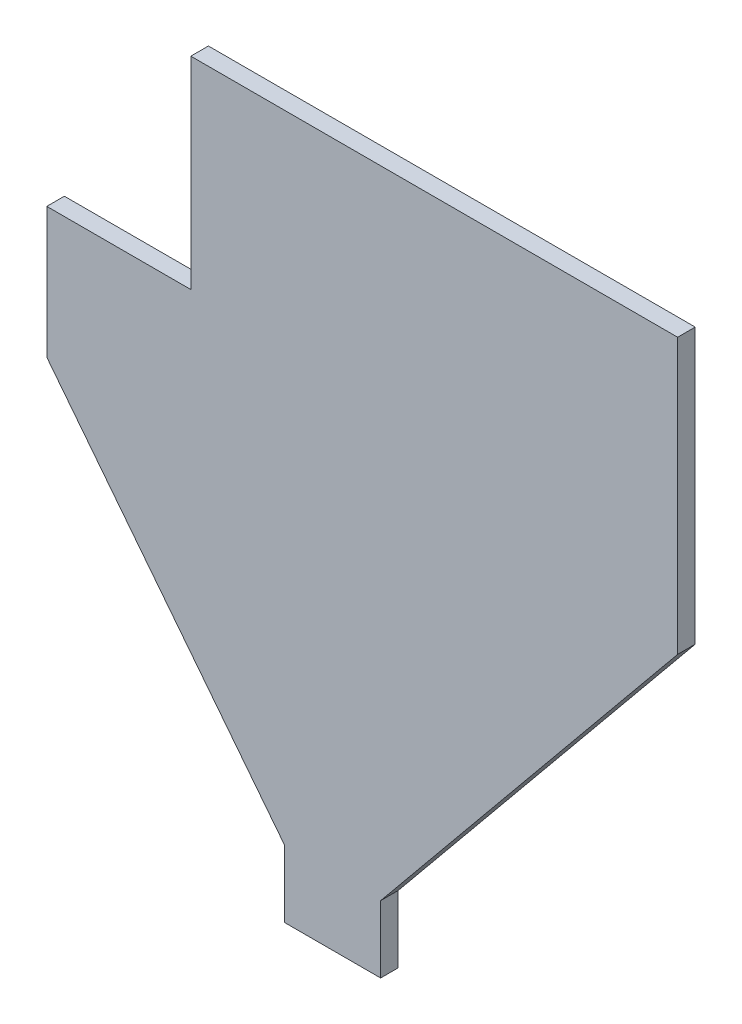
from build123d import *

# Parameters (mm, degrees)
BOSS_EXTRU_1_DEPTH = 2


with BuildPart() as part:
    # Esquisse1 → Boss.-Extru.1 (new body)
    with BuildSketch(Plane.XY):
        Polygon((-16.129, -1.27), (-16.129, -24.257), (-32.512, -24.257), (-32.512, -39.116), (-5.461, -73.66), (-5.461, -81.28), (5.461, -81.28), (5.461, -73.66), (39.243, -32.512), (39.243, -1.27), align=None)
    extrude(amount=BOSS_EXTRU_1_DEPTH)


solid = part.part
